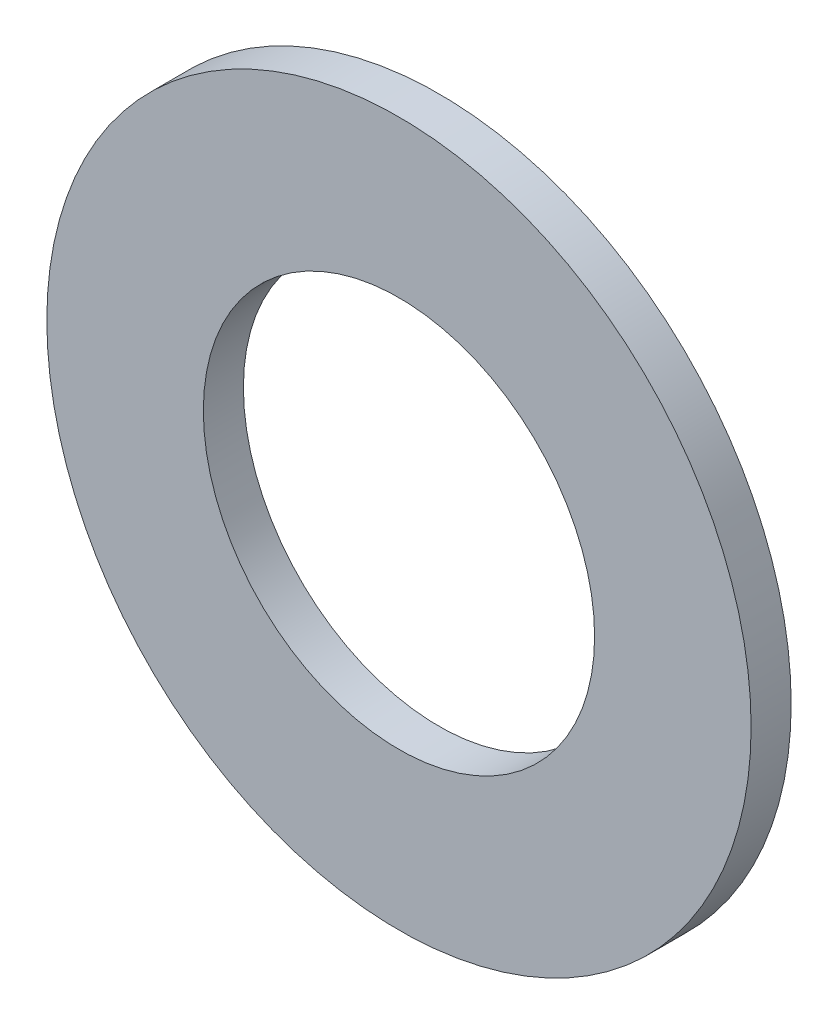
from build123d import *

# Parameters (mm, degrees)
SKETCH1_R           = 7.14375
SKETCH1_R_2         = 3.96875
BOSS_EXTRUDE1_DEPTH = 0.8128


with BuildPart() as part:
    # Sketch1 → Boss-Extrude1 (new body)
    with BuildSketch(Plane.XY):
        Circle(SKETCH1_R)
        Circle(SKETCH1_R_2, mode=Mode.SUBTRACT)
    extrude(amount=BOSS_EXTRUDE1_DEPTH)


solid = part.part
